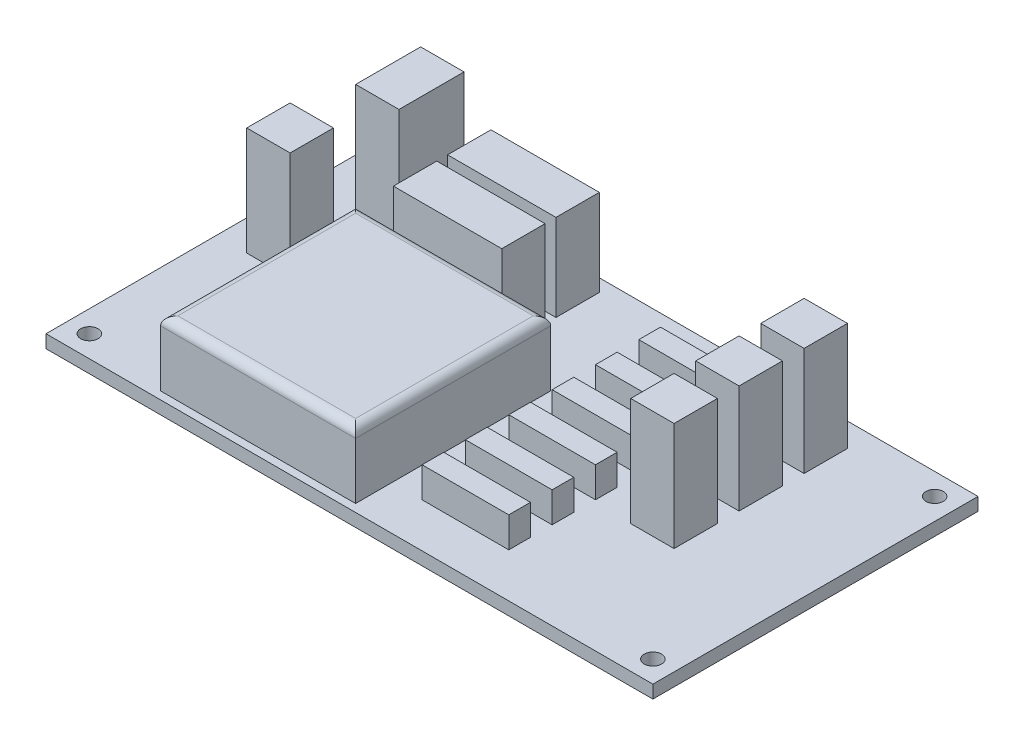
from build123d import *

# Parameters (mm, degrees)
ESQUISSE1_W      = 140
ESQUISSE1_H      = 75
ESQUISSE1_R      = 2
EXTRUSION1_DEPTH = 3
ESQUISSE2_W      = 45
ESQUISSE2_H      = 45
EXTRUSION2_DEPTH = 15
CONG_1_R         = 2
ESQUISSE3_W      = 10
ESQUISSE3_H      = 10
EXTRUSION3_DEPTH = 25
ESQUISSE4_W      = 25
ESQUISSE4_H      = 10
EXTRUSION4_DEPTH = 20
ESQUISSE5_W      = 20
ESQUISSE5_H      = 5
EXTRUSION5_DEPTH = 7
ESQUISSE6_W      = 10
ESQUISSE6_H      = 15
EXTRUSION6_DEPTH = 25


with BuildPart() as part:
    # Esquisse1 → Extrusion1 (new body)
    with BuildSketch(Plane(origin=(0, 0, 0), x_dir=(1, 0, 0), z_dir=(0, 1, 0))):
        with Locations((70, 37.5)):
            Rectangle(ESQUISSE1_W, ESQUISSE1_H)
        with Locations((5, 70)):
            Circle(ESQUISSE1_R, mode=Mode.SUBTRACT)
        with Locations((135, 70)):
            Circle(ESQUISSE1_R, mode=Mode.SUBTRACT)
        with Locations((135, 5)):
            Circle(ESQUISSE1_R, mode=Mode.SUBTRACT)
        with Locations((5, 5)):
            Circle(ESQUISSE1_R, mode=Mode.SUBTRACT)
    extrude(amount=EXTRUSION1_DEPTH)

    # Esquisse2 → Extrusion2 (add)
    with BuildSketch(Plane(origin=(0, 3, 0), x_dir=(1, 0, 0), z_dir=(0, 1, 0))):
        with Locations((47.129827859, 24.288749044)):
            Rectangle(ESQUISSE2_W, ESQUISSE2_H)
    extrude(amount=EXTRUSION2_DEPTH)

    # Congé1
    cong_1_edges = [part.edges().sort_by_distance(p)[0] for p in [
        (24.629827859, 18, -24.288749044),
        (47.129827859, 18, -1.788749044),
        (69.629827859, 18, -24.288749044),
        (47.129827859, 18, -46.788749044),
    ]]
    fillet(cong_1_edges, radius=CONG_1_R)

    # Esquisse3 → Extrusion3 (add)
    with BuildSketch(Plane(origin=(0, 3, 0), x_dir=(1, 0, 0), z_dir=(0, 1, 0))):
        with Locations((110.370603903, 64.515282671)):
            Rectangle(ESQUISSE3_W, ESQUISSE3_H)
        with Locations((12.038471753, 44.271083815)):
            Rectangle(ESQUISSE3_W, ESQUISSE3_H)
        with Locations((110.370603903, 49.515282671)):
            Rectangle(ESQUISSE3_W, ESQUISSE3_H)
        with Locations((110.370603903, 34.515282671)):
            Rectangle(ESQUISSE3_W, ESQUISSE3_H)
    extrude(amount=EXTRUSION3_DEPTH)

    # Esquisse4 → Extrusion4 (add)
    with BuildSketch(Plane(origin=(0, 3, 0), x_dir=(1, 0, 0), z_dir=(0, 1, 0))):
        with Locations((43.077660713, 67.06403932)):
            Rectangle(ESQUISSE4_W, ESQUISSE4_H)
        with Locations((43.077660713, 54.56403932)):
            Rectangle(ESQUISSE4_W, ESQUISSE4_H)
    extrude(amount=EXTRUSION4_DEPTH)

    # Esquisse5 → Extrusion5 (add)
    with BuildSketch(Plane(origin=(0, 3, 0), x_dir=(1, 0, 0), z_dir=(0, 1, 0))):
        with Locations((86.557419786, 62.697517929)):
            Rectangle(ESQUISSE5_W, ESQUISSE5_H)
        with Locations((86.557419786, 52.697517929)):
            Rectangle(ESQUISSE5_W, ESQUISSE5_H)
        with Locations((86.557419786, 42.697517929)):
            Rectangle(ESQUISSE5_W, ESQUISSE5_H)
        with Locations((86.557419786, 32.697517929)):
            Rectangle(ESQUISSE5_W, ESQUISSE5_H)
        with Locations((86.557419786, 22.697517929)):
            Rectangle(ESQUISSE5_W, ESQUISSE5_H)
        with Locations((86.557419786, 12.697517929)):
            Rectangle(ESQUISSE5_W, ESQUISSE5_H)
    extrude(amount=EXTRUSION5_DEPTH)

    # Esquisse6 → Extrusion6 (add)
    with BuildSketch(Plane(origin=(0, 3, 0), x_dir=(1, 0, 0), z_dir=(0, 1, 0))):
        with Locations((15.904188898, 68.024450773)):
            Rectangle(ESQUISSE6_W, ESQUISSE6_H)
    extrude(amount=EXTRUSION6_DEPTH)


solid = part.part
